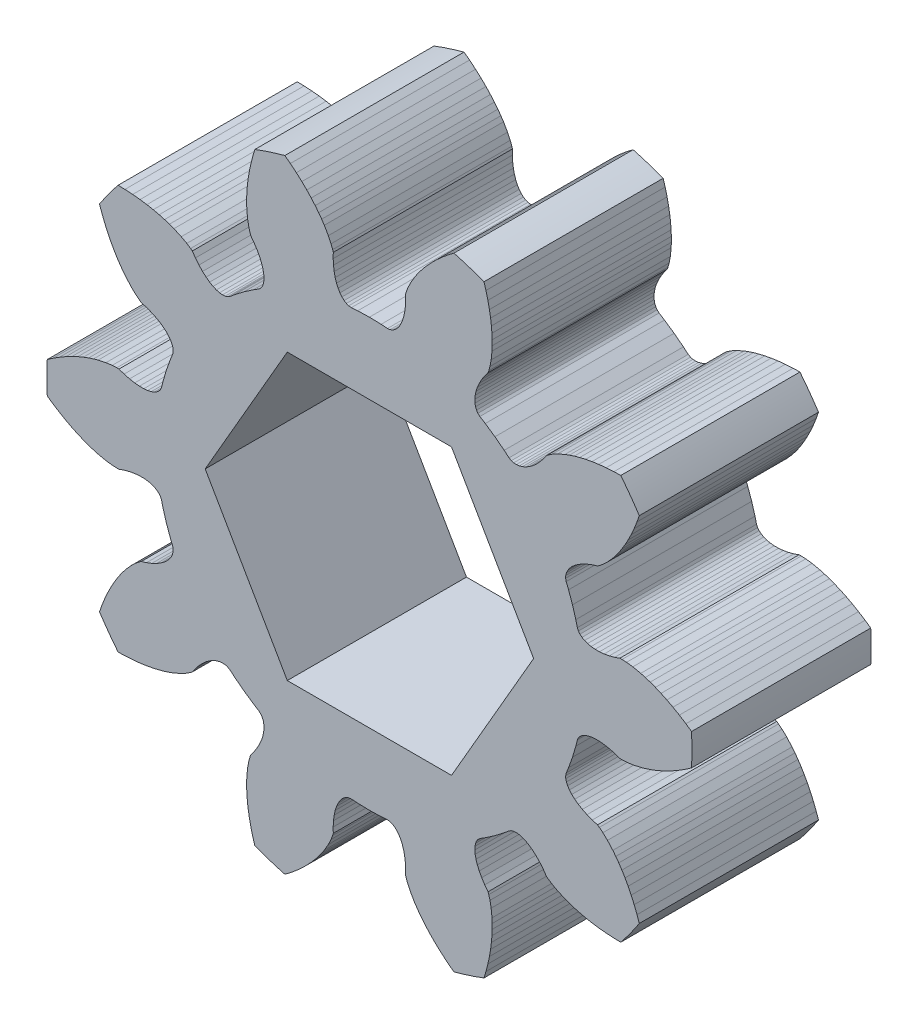
from build123d import *

# Parameters (mm, degrees)
BOSS_EXTRUDE1_DEPTH = 3


with BuildPart() as part:
    # Model → Boss-Extrude1 (new body, symmetric)
    with BuildSketch(Plane.XY):
        with BuildLine():
            Line((8.9615234, 5.6957215), (8.8657208, 5.4530286))
            Line((8.8657208, 5.4530286), (8.7654123, 5.227083))
            Line((8.7654123, 5.227083), (8.6629778, 5.0201721))
            Line((8.6629778, 5.0201721), (8.5591228, 4.8306744))
            Line((8.5591228, 4.8306744), (8.4540092, 4.6566029))
            Line((8.4540092, 4.6566029), (8.3503228, 4.5001444))
            Line((8.3503228, 4.5001444), (8.2497142, 4.3612991))
            Line((8.2497142, 4.3612991), (8.1507015, 4.2360525))
            Line((8.1507015, 4.2360525), (7.9707853, 4.0353208))
            Line((7.9707853, 4.0353208), (7.8171849, 3.8902241))
            Line((7.8171849, 3.8902241), (7.6984707, 3.7953878))
            Line((7.6984707, 3.7953878), (7.6379027, 3.7538481))
            Line((7.6379027, 3.7538481), (7.4633429, 3.7005054))
            Line((7.4633429, 3.7005054), (7.2880277, 3.6330485))
            Line((7.2880277, 3.6330485), (7.1314652, 3.5580682))
            Line((7.1314652, 3.5580682), (6.9939731, 3.4770137))
            Line((6.9939731, 3.4770137), (6.8757521, 3.3913382))
            Line((6.8757521, 3.3913382), (6.7769085, 3.3025271))
            Line((6.7769085, 3.3025271), (6.6974849, 3.2120348))
            Line((6.6974849, 3.2120348), (6.6374198, 3.121345))
            Line((6.6374198, 3.121345), (6.5965502, 3.0318978))
            Line((6.5965502, 3.0318978), (6.5746533, 2.9451558))
            Line((6.5746533, 2.9451558), (6.5714011, 2.8625161))
            Line((6.5714011, 2.8625161), (6.5895052, 2.7762168))
            Line((6.5895052, 2.7762168), (6.6688945, 2.5785132))
            Line((6.6688945, 2.5785132), (6.8000541, 2.2094715))
            Line((6.8000541, 2.2094715), (6.910861, 1.8338169))
            Line((6.910861, 1.8338169), (6.962841, 1.6272074))
            Line((6.962841, 1.6272074), (6.99892, 1.5467485))
            Line((6.99892, 1.5467485), (7.0501253, 1.4818032))
            Line((7.0501253, 1.4818032), (7.118826, 1.4244981))
            Line((7.118826, 1.4244981), (7.204466, 1.3761563))
            Line((7.204466, 1.3761563), (7.3063658, 1.3380921))
            Line((7.3063658, 1.3380921), (7.4238109, 1.3115663))
            Line((7.4238109, 1.3115663), (7.5559789, 1.2978155))
            Line((7.5559789, 1.2978155), (7.7019805, 1.2979911))
            Line((7.7019805, 1.2979911), (7.8608566, 1.3132324))
            Line((7.8608566, 1.3132324), (8.0315906, 1.3445973))
            Line((8.0315906, 1.3445973), (8.2130738, 1.3930711))
            Line((8.2130738, 1.3930711), (8.3856497, 1.4525196))
            Line((8.3856497, 1.4525196), (8.4590665, 1.4545143))
            Line((8.4590665, 1.4545143), (8.6108518, 1.4475686))
            Line((8.6108518, 1.4475686), (8.8204028, 1.420467))
            Line((8.8204028, 1.420467), (9.0839452, 1.3638237))
            Line((9.0839452, 1.3638237), (9.2376663, 1.3206953))
            Line((9.2376663, 1.3206953), (9.4006716, 1.2675033))
            Line((9.4006716, 1.2675033), (9.5765196, 1.2018711))
            Line((9.5765196, 1.2018711), (9.763875, 1.1228284))
            Line((9.763875, 1.1228284), (9.9592794, 1.0305661))
            Line((9.9592794, 1.0305661), (10.1637699, 0.9233811))
            Line((10.1637699, 0.9233811), (10.3777285, 0.7995471))
            Line((10.3777285, 0.7995471), (10.5978859, 0.6595158))
            Line((10.5978859, 0.6595158), (10.7870004, 0.5284416))
            ThreePointArc((10.7870004, 0.5284416), (10.799936412, 0), (10.7870004, -0.5284416))
            Line((10.7870004, -0.5284416), (10.5978859, -0.6595158))
            Line((10.5978859, -0.6595158), (10.3777285, -0.7995471))
            Line((10.3777285, -0.7995471), (10.1637699, -0.9233811))
            Line((10.1637699, -0.9233811), (9.9592794, -1.0305661))
            Line((9.9592794, -1.0305661), (9.763875, -1.1228284))
            Line((9.763875, -1.1228284), (9.5765196, -1.2018711))
            Line((9.5765196, -1.2018711), (9.4006716, -1.2675033))
            Line((9.4006716, -1.2675033), (9.2376663, -1.3206953))
            Line((9.2376663, -1.3206953), (9.0839452, -1.3638237))
            Line((9.0839452, -1.3638237), (8.8204028, -1.420467))
            Line((8.8204028, -1.420467), (8.6108518, -1.4475686))
            Line((8.6108518, -1.4475686), (8.4590665, -1.4545143))
            Line((8.4590665, -1.4545143), (8.3856497, -1.4525196))
            Line((8.3856497, -1.4525196), (8.2130738, -1.3930711))
            Line((8.2130738, -1.3930711), (8.0315906, -1.3445973))
            Line((8.0315906, -1.3445973), (7.8608566, -1.3132324))
            Line((7.8608566, -1.3132324), (7.7019805, -1.2979911))
            Line((7.7019805, -1.2979911), (7.5559789, -1.2978155))
            Line((7.5559789, -1.2978155), (7.4238109, -1.3115663))
            Line((7.4238109, -1.3115663), (7.3063658, -1.3380921))
            Line((7.3063658, -1.3380921), (7.204466, -1.3761563))
            Line((7.204466, -1.3761563), (7.118826, -1.4244981))
            Line((7.118826, -1.4244981), (7.0501253, -1.4818032))
            Line((7.0501253, -1.4818032), (6.99892, -1.5467485))
            Line((6.99892, -1.5467485), (6.962841, -1.6272074))
            Line((6.962841, -1.6272074), (6.910861, -1.8338169))
            Line((6.910861, -1.8338169), (6.8000541, -2.2094715))
            Line((6.8000541, -2.2094715), (6.6688945, -2.5785132))
            Line((6.6688945, -2.5785132), (6.5895052, -2.7762168))
            Line((6.5895052, -2.7762168), (6.5714011, -2.8625161))
            Line((6.5714011, -2.8625161), (6.5746533, -2.9451558))
            Line((6.5746533, -2.9451558), (6.5965502, -3.0318978))
            Line((6.5965502, -3.0318978), (6.6374198, -3.121345))
            Line((6.6374198, -3.121345), (6.6974849, -3.2120348))
            Line((6.6974849, -3.2120348), (6.7769085, -3.3025271))
            Line((6.7769085, -3.3025271), (6.8757521, -3.3913382))
            Line((6.8757521, -3.3913382), (6.9939731, -3.4770137))
            Line((6.9939731, -3.4770137), (7.1314652, -3.5580682))
            Line((7.1314652, -3.5580682), (7.2880277, -3.6330485))
            Line((7.2880277, -3.6330485), (7.4633429, -3.7005054))
            Line((7.4633429, -3.7005054), (7.6379027, -3.7538481))
            Line((7.6379027, -3.7538481), (7.6984707, -3.7953878))
            Line((7.6984707, -3.7953878), (7.8171849, -3.8902241))
            Line((7.8171849, -3.8902241), (7.9707853, -4.0353208))
            Line((7.9707853, -4.0353208), (8.1507015, -4.2360525))
            Line((8.1507015, -4.2360525), (8.2497142, -4.3612991))
            Line((8.2497142, -4.3612991), (8.3503228, -4.5001444))
            Line((8.3503228, -4.5001444), (8.4540092, -4.6566029))
            Line((8.4540092, -4.6566029), (8.5591228, -4.8306744))
            Line((8.5591228, -4.8306744), (8.6629778, -5.0201721))
            Line((8.6629778, -5.0201721), (8.7654123, -5.227083))
            Line((8.7654123, -5.227083), (8.8657208, -5.4530286))
            Line((8.8657208, -5.4530286), (8.9615234, -5.6957215))
            Line((8.9615234, -5.6957215), (9.0374768, -5.9129215))
            ThreePointArc((9.0374768, -5.9129215), (8.737332104, -6.348043346), (8.4162565, -6.767958))
            Line((8.4162565, -6.767958), (8.1862161, -6.7628405))
            Line((8.1862161, -6.7628405), (7.9257968, -6.746723))
            Line((7.9257968, -6.746723), (7.6799127, -6.721145))
            Line((7.6799127, -6.721145), (7.4514747, -6.687663))
            Line((7.4514747, -6.687663), (7.2391588, -6.647449))
            Line((7.2391588, -6.647449), (7.041125, -6.6012711))
            Line((7.041125, -6.6012711), (6.8602833, -6.5510078))
            Line((6.8602833, -6.5510078), (6.6971438, -6.4982289))
            Line((6.6971438, -6.4982289), (6.5474306, -6.4427656))
            Line((6.5474306, -6.4427656), (6.3009262, -6.3336846))
            Line((6.3009262, -6.3336846), (6.115466, -6.2324393))
            Line((6.115466, -6.2324393), (5.9885865, -6.1488414))
            Line((5.9885865, -6.1488414), (5.9303635, -6.1040743))
            Line((5.9303635, -6.1040743), (5.8256896, -5.9545419))
            Line((5.8256896, -5.9545419), (5.7073589, -5.8086526))
            Line((5.7073589, -5.8086526), (5.5876679, -5.6829229))
            Line((5.5876679, -5.6829229), (5.4680931, -5.5772074))
            Line((5.4680931, -5.5772074), (5.3500785, -5.4912477))
            Line((5.3500785, -5.4912477), (5.2350698, -5.424686))
            Line((5.2350698, -5.424686), (5.1244633, -5.3771133))
            Line((5.1244633, -5.3771133), (5.019651, -5.3480127))
            Line((5.019651, -5.3480127), (4.9219522, -5.3367841))
            Line((4.9219522, -5.3367841), (4.8326892, -5.3427636))
            Line((4.8326892, -5.3427636), (4.7530893, -5.3652077))
            Line((4.7530893, -5.3652077), (4.6766082, -5.4090937))
            Line((4.6766082, -5.4090937), (4.5131135, -5.5456912))
            Line((4.5131135, -5.5456912), (4.2026646, -5.7844715))
            Line((4.2026646, -5.7844715), (3.879637, -6.0059388))
            Line((3.879637, -6.0059388), (3.6992024, -6.1192205))
            Line((3.6992024, -6.1192205), (3.6338304, -6.1783969))
            Line((3.6338304, -6.1783969), (3.5878871, -6.2471653))
            Line((3.5878871, -6.2471653), (3.5546164, -6.3302117))
            Line((3.5546164, -6.3302117), (3.5351048, -6.4265986))
            Line((3.5351048, -6.4265986), (3.5303924, -6.5352736))
            Line((3.5303924, -6.5352736), (3.5414574, -6.6551674))
            Line((3.5414574, -6.6551674), (3.5692218, -6.7851159))
            Line((3.5692218, -6.7851159), (3.6145057, -6.9239174))
            Line((3.6145057, -6.9239174), (3.6780965, -7.0703077))
            Line((3.6780965, -7.0703077), (3.760686, -7.2229932))
            Line((3.760686, -7.2229932), (3.8628688, -7.3806147))
            Line((3.8628688, -7.3806147), (3.9727365, -7.5263735))
            Line((3.9727365, -7.5263735), (3.9973206, -7.5955807))
            Line((3.9973206, -7.5955807), (4.0376191, -7.7420834))
            Line((4.0376191, -7.7420834), (4.0765987, -7.9497531))
            Line((4.0765987, -7.9497531), (4.1041669, -8.2179006))
            Line((4.1041669, -8.2179006), (4.1106517, -8.3774254))
            Line((4.1106517, -8.3774254), (4.1104345, -8.5488899))
            Line((4.1104345, -8.5488899), (4.1023546, -8.7364128))
            Line((4.1023546, -8.7364128), (4.0850766, -8.9390239))
            Line((4.0850766, -8.9390239), (4.0577132, -9.1533751))
            Line((4.0577132, -9.1533751), (4.0189652, -9.3809791))
            Line((4.0189652, -9.3809791), (3.967309, -9.6227327))
            Line((3.967309, -9.6227327), (3.9021637, -9.8753868))
            Line((3.9021637, -9.8753868), (3.8359442, -10.0957496))
            ThreePointArc((3.8359442, -10.0957496), (3.337363848, -10.271349928), (2.8307886, -10.4223445))
            Line((2.8307886, -10.4223445), (2.64769, -10.28299))
            Line((2.64769, -10.28299), (2.44648, -10.11688))
            Line((2.44648, -10.11688), (2.26259, -9.95166))
            Line((2.26259, -9.95166), (2.09746, -9.7903))
            Line((2.09746, -9.7903), (1.94933, -9.63297))
            Line((1.94933, -9.63297), (1.81626, -9.47921))
            Line((1.81626, -9.47921), (1.6995, -9.33225))
            Line((1.6995, -9.33225), (1.59854, -9.19366))
            Line((1.59854, -9.19366), (1.51002, -9.06079))
            Line((1.51002, -9.06079), (1.37471, -8.82765))
            Line((1.37471, -8.82765), (1.28418, -8.63673))
            Line((1.28418, -8.63673), (1.23067, -8.49452))
            Line((1.23067, -8.49452), (1.20988, -8.42408))
            Line((1.20988, -8.42408), (1.21309, -8.24158))
            Line((1.21309, -8.24158), (1.20311, -8.054))
            Line((1.20311, -8.054), (1.18018, -7.88193))
            Line((1.18018, -7.88193), (1.14558, -7.72612))
            Line((1.14558, -7.72612), (1.10063, -7.58721))
            Line((1.10063, -7.58721), (1.04671, -7.46576))
            Line((1.04671, -7.46576), (0.98519, -7.36226))
            Line((0.98519, -7.36226), (0.9175, -7.27711))
            Line((0.9175, -7.27711), (0.84506, -7.2106))
            Line((0.84506, -7.2106), (0.76933, -7.16297))
            Line((0.76933, -7.16297), (0.69174, -7.13434))
            Line((0.69174, -7.13434), (0.60407, -7.12489))
            Line((0.60407, -7.12489), (0.39151, -7.1393))
            Line((0.39151, -7.1393), (0, -7.15))
            Line((0, -7.15), (-0.39151, -7.1393))
            Line((-0.39151, -7.1393), (-0.60407, -7.12489))
            Line((-0.60407, -7.12489), (-0.69174, -7.13434))
            Line((-0.69174, -7.13434), (-0.76933, -7.16297))
            Line((-0.76933, -7.16297), (-0.84506, -7.2106))
            Line((-0.84506, -7.2106), (-0.9175, -7.27711))
            Line((-0.9175, -7.27711), (-0.98519, -7.36226))
            Line((-0.98519, -7.36226), (-1.04671, -7.46576))
            Line((-1.04671, -7.46576), (-1.10063, -7.58721))
            Line((-1.10063, -7.58721), (-1.14558, -7.72612))
            Line((-1.14558, -7.72612), (-1.18018, -7.88193))
            Line((-1.18018, -7.88193), (-1.20311, -8.054))
            Line((-1.20311, -8.054), (-1.21309, -8.24158))
            Line((-1.21309, -8.24158), (-1.20988, -8.42408))
            Line((-1.20988, -8.42408), (-1.23067, -8.49452))
            Line((-1.23067, -8.49452), (-1.28418, -8.63673))
            Line((-1.28418, -8.63673), (-1.37471, -8.82765))
            Line((-1.37471, -8.82765), (-1.51002, -9.06079))
            Line((-1.51002, -9.06079), (-1.59854, -9.19366))
            Line((-1.59854, -9.19366), (-1.6995, -9.33225))
            Line((-1.6995, -9.33225), (-1.81626, -9.47921))
            Line((-1.81626, -9.47921), (-1.94933, -9.63297))
            Line((-1.94933, -9.63297), (-2.09746, -9.7903))
            Line((-2.09746, -9.7903), (-2.26259, -9.95166))
            Line((-2.26259, -9.95166), (-2.44648, -10.11688))
            Line((-2.44648, -10.11688), (-2.64769, -10.28299))
            Line((-2.64769, -10.28299), (-2.8307886, -10.4223445))
            ThreePointArc((-2.8307886, -10.4223445), (-3.337363848, -10.271349928), (-3.8359442, -10.0957496))
            Line((-3.8359442, -10.0957496), (-3.9021637, -9.8753868))
            Line((-3.9021637, -9.8753868), (-3.967309, -9.6227327))
            Line((-3.967309, -9.6227327), (-4.0189652, -9.3809791))
            Line((-4.0189652, -9.3809791), (-4.0577132, -9.1533751))
            Line((-4.0577132, -9.1533751), (-4.0850766, -8.9390239))
            Line((-4.0850766, -8.9390239), (-4.1023546, -8.7364128))
            Line((-4.1023546, -8.7364128), (-4.1104345, -8.5488899))
            Line((-4.1104345, -8.5488899), (-4.1106517, -8.3774254))
            Line((-4.1106517, -8.3774254), (-4.1041669, -8.2179006))
            Line((-4.1041669, -8.2179006), (-4.0765987, -7.9497531))
            Line((-4.0765987, -7.9497531), (-4.0376191, -7.7420834))
            Line((-4.0376191, -7.7420834), (-3.9973206, -7.5955807))
            Line((-3.9973206, -7.5955807), (-3.9727365, -7.5263735))
            Line((-3.9727365, -7.5263735), (-3.8628688, -7.3806147))
            Line((-3.8628688, -7.3806147), (-3.760686, -7.2229932))
            Line((-3.760686, -7.2229932), (-3.6780965, -7.0703077))
            Line((-3.6780965, -7.0703077), (-3.6145057, -6.9239174))
            Line((-3.6145057, -6.9239174), (-3.5692218, -6.7851159))
            Line((-3.5692218, -6.7851159), (-3.5414574, -6.6551674))
            Line((-3.5414574, -6.6551674), (-3.5303924, -6.5352736))
            Line((-3.5303924, -6.5352736), (-3.5351048, -6.4265986))
            Line((-3.5351048, -6.4265986), (-3.5546164, -6.3302117))
            Line((-3.5546164, -6.3302117), (-3.5878871, -6.2471653))
            Line((-3.5878871, -6.2471653), (-3.6338304, -6.1783969))
            Line((-3.6338304, -6.1783969), (-3.6992024, -6.1192205))
            Line((-3.6992024, -6.1192205), (-3.879637, -6.0059388))
            Line((-3.879637, -6.0059388), (-4.2026646, -5.7844715))
            Line((-4.2026646, -5.7844715), (-4.5131135, -5.5456912))
            Line((-4.5131135, -5.5456912), (-4.6766082, -5.4090937))
            Line((-4.6766082, -5.4090937), (-4.7530893, -5.3652077))
            Line((-4.7530893, -5.3652077), (-4.8326892, -5.3427636))
            Line((-4.8326892, -5.3427636), (-4.9219522, -5.3367841))
            Line((-4.9219522, -5.3367841), (-5.019651, -5.3480127))
            Line((-5.019651, -5.3480127), (-5.1244633, -5.3771133))
            Line((-5.1244633, -5.3771133), (-5.2350698, -5.424686))
            Line((-5.2350698, -5.424686), (-5.3500785, -5.4912477))
            Line((-5.3500785, -5.4912477), (-5.4680931, -5.5772074))
            Line((-5.4680931, -5.5772074), (-5.5876679, -5.6829229))
            Line((-5.5876679, -5.6829229), (-5.7073589, -5.8086526))
            Line((-5.7073589, -5.8086526), (-5.8256896, -5.9545419))
            Line((-5.8256896, -5.9545419), (-5.9303635, -6.1040743))
            Line((-5.9303635, -6.1040743), (-5.9885865, -6.1488414))
            Line((-5.9885865, -6.1488414), (-6.115466, -6.2324393))
            Line((-6.115466, -6.2324393), (-6.3009262, -6.3336846))
            Line((-6.3009262, -6.3336846), (-6.5474306, -6.4427656))
            Line((-6.5474306, -6.4427656), (-6.6971438, -6.4982289))
            Line((-6.6971438, -6.4982289), (-6.8602833, -6.5510078))
            Line((-6.8602833, -6.5510078), (-7.041125, -6.6012711))
            Line((-7.041125, -6.6012711), (-7.2391588, -6.647449))
            Line((-7.2391588, -6.647449), (-7.4514747, -6.687663))
            Line((-7.4514747, -6.687663), (-7.6799127, -6.721145))
            Line((-7.6799127, -6.721145), (-7.9257968, -6.746723))
            Line((-7.9257968, -6.746723), (-8.1862161, -6.7628405))
            Line((-8.1862161, -6.7628405), (-8.4162565, -6.767958))
            ThreePointArc((-8.4162565, -6.767958), (-8.737332104, -6.348043346), (-9.0374768, -5.9129215))
            Line((-9.0374768, -5.9129215), (-8.9615234, -5.6957215))
            Line((-8.9615234, -5.6957215), (-8.8657208, -5.4530286))
            Line((-8.8657208, -5.4530286), (-8.7654123, -5.227083))
            Line((-8.7654123, -5.227083), (-8.6629778, -5.0201721))
            Line((-8.6629778, -5.0201721), (-8.5591228, -4.8306744))
            Line((-8.5591228, -4.8306744), (-8.4540092, -4.6566029))
            Line((-8.4540092, -4.6566029), (-8.3503228, -4.5001444))
            Line((-8.3503228, -4.5001444), (-8.2497142, -4.3612991))
            Line((-8.2497142, -4.3612991), (-8.1507015, -4.2360525))
            Line((-8.1507015, -4.2360525), (-7.9707853, -4.0353208))
            Line((-7.9707853, -4.0353208), (-7.8171849, -3.8902241))
            Line((-7.8171849, -3.8902241), (-7.6984707, -3.7953878))
            Line((-7.6984707, -3.7953878), (-7.6379027, -3.7538481))
            Line((-7.6379027, -3.7538481), (-7.4633429, -3.7005054))
            Line((-7.4633429, -3.7005054), (-7.2880277, -3.6330485))
            Line((-7.2880277, -3.6330485), (-7.1314652, -3.5580682))
            Line((-7.1314652, -3.5580682), (-6.9939731, -3.4770137))
            Line((-6.9939731, -3.4770137), (-6.8757521, -3.3913382))
            Line((-6.8757521, -3.3913382), (-6.7769085, -3.3025271))
            Line((-6.7769085, -3.3025271), (-6.6974849, -3.2120348))
            Line((-6.6974849, -3.2120348), (-6.6374198, -3.121345))
            Line((-6.6374198, -3.121345), (-6.5965502, -3.0318978))
            Line((-6.5965502, -3.0318978), (-6.5746533, -2.9451558))
            Line((-6.5746533, -2.9451558), (-6.5714011, -2.8625161))
            Line((-6.5714011, -2.8625161), (-6.5895052, -2.7762168))
            Line((-6.5895052, -2.7762168), (-6.6688945, -2.5785132))
            Line((-6.6688945, -2.5785132), (-6.8000541, -2.2094715))
            Line((-6.8000541, -2.2094715), (-6.910861, -1.8338169))
            Line((-6.910861, -1.8338169), (-6.962841, -1.6272074))
            Line((-6.962841, -1.6272074), (-6.99892, -1.5467485))
            Line((-6.99892, -1.5467485), (-7.0501253, -1.4818032))
            Line((-7.0501253, -1.4818032), (-7.118826, -1.4244981))
            Line((-7.118826, -1.4244981), (-7.204466, -1.3761563))
            Line((-7.204466, -1.3761563), (-7.3063658, -1.3380921))
            Line((-7.3063658, -1.3380921), (-7.4238109, -1.3115663))
            Line((-7.4238109, -1.3115663), (-7.5559789, -1.2978155))
            Line((-7.5559789, -1.2978155), (-7.7019805, -1.2979911))
            Line((-7.7019805, -1.2979911), (-7.8608566, -1.3132324))
            Line((-7.8608566, -1.3132324), (-8.0315906, -1.3445973))
            Line((-8.0315906, -1.3445973), (-8.2130738, -1.3930711))
            Line((-8.2130738, -1.3930711), (-8.3856497, -1.4525196))
            Line((-8.3856497, -1.4525196), (-8.4590665, -1.4545143))
            Line((-8.4590665, -1.4545143), (-8.6108518, -1.4475686))
            Line((-8.6108518, -1.4475686), (-8.8204028, -1.420467))
            Line((-8.8204028, -1.420467), (-9.0839452, -1.3638237))
            Line((-9.0839452, -1.3638237), (-9.2376663, -1.3206953))
            Line((-9.2376663, -1.3206953), (-9.4006716, -1.2675033))
            Line((-9.4006716, -1.2675033), (-9.5765196, -1.2018711))
            Line((-9.5765196, -1.2018711), (-9.763875, -1.1228284))
            Line((-9.763875, -1.1228284), (-9.9592794, -1.0305661))
            Line((-9.9592794, -1.0305661), (-10.1637699, -0.9233811))
            Line((-10.1637699, -0.9233811), (-10.3777285, -0.7995471))
            Line((-10.3777285, -0.7995471), (-10.5978859, -0.6595158))
            Line((-10.5978859, -0.6595158), (-10.7870004, -0.5284416))
            ThreePointArc((-10.7870004, -0.5284416), (-10.799936412, 0), (-10.7870004, 0.5284416))
            Line((-10.7870004, 0.5284416), (-10.5978859, 0.6595158))
            Line((-10.5978859, 0.6595158), (-10.3777285, 0.7995471))
            Line((-10.3777285, 0.7995471), (-10.1637699, 0.9233811))
            Line((-10.1637699, 0.9233811), (-9.9592794, 1.0305661))
            Line((-9.9592794, 1.0305661), (-9.763875, 1.1228284))
            Line((-9.763875, 1.1228284), (-9.5765196, 1.2018711))
            Line((-9.5765196, 1.2018711), (-9.4006716, 1.2675033))
            Line((-9.4006716, 1.2675033), (-9.2376663, 1.3206953))
            Line((-9.2376663, 1.3206953), (-9.0839452, 1.3638237))
            Line((-9.0839452, 1.3638237), (-8.8204028, 1.420467))
            Line((-8.8204028, 1.420467), (-8.6108518, 1.4475686))
            Line((-8.6108518, 1.4475686), (-8.4590665, 1.4545143))
            Line((-8.4590665, 1.4545143), (-8.3856497, 1.4525196))
            Line((-8.3856497, 1.4525196), (-8.2130738, 1.3930711))
            Line((-8.2130738, 1.3930711), (-8.0315906, 1.3445973))
            Line((-8.0315906, 1.3445973), (-7.8608566, 1.3132324))
            Line((-7.8608566, 1.3132324), (-7.7019805, 1.2979911))
            Line((-7.7019805, 1.2979911), (-7.5559789, 1.2978155))
            Line((-7.5559789, 1.2978155), (-7.4238109, 1.3115663))
            Line((-7.4238109, 1.3115663), (-7.3063658, 1.3380921))
            Line((-7.3063658, 1.3380921), (-7.204466, 1.3761563))
            Line((-7.204466, 1.3761563), (-7.118826, 1.4244981))
            Line((-7.118826, 1.4244981), (-7.0501253, 1.4818032))
            Line((-7.0501253, 1.4818032), (-6.99892, 1.5467485))
            Line((-6.99892, 1.5467485), (-6.962841, 1.6272074))
            Line((-6.962841, 1.6272074), (-6.910861, 1.8338169))
            Line((-6.910861, 1.8338169), (-6.8000541, 2.2094715))
            Line((-6.8000541, 2.2094715), (-6.6688945, 2.5785132))
            Line((-6.6688945, 2.5785132), (-6.5895052, 2.7762168))
            Line((-6.5895052, 2.7762168), (-6.5714011, 2.8625161))
            Line((-6.5714011, 2.8625161), (-6.5746533, 2.9451558))
            Line((-6.5746533, 2.9451558), (-6.5965502, 3.0318978))
            Line((-6.5965502, 3.0318978), (-6.6374198, 3.121345))
            Line((-6.6374198, 3.121345), (-6.6974849, 3.2120348))
            Line((-6.6974849, 3.2120348), (-6.7769085, 3.3025271))
            Line((-6.7769085, 3.3025271), (-6.8757521, 3.3913382))
            Line((-6.8757521, 3.3913382), (-6.9939731, 3.4770137))
            Line((-6.9939731, 3.4770137), (-7.1314652, 3.5580682))
            Line((-7.1314652, 3.5580682), (-7.2880277, 3.6330485))
            Line((-7.2880277, 3.6330485), (-7.4633429, 3.7005054))
            Line((-7.4633429, 3.7005054), (-7.6379027, 3.7538481))
            Line((-7.6379027, 3.7538481), (-7.6984707, 3.7953878))
            Line((-7.6984707, 3.7953878), (-7.8171849, 3.8902241))
            Line((-7.8171849, 3.8902241), (-7.9707853, 4.0353208))
            Line((-7.9707853, 4.0353208), (-8.1507015, 4.2360525))
            Line((-8.1507015, 4.2360525), (-8.2497142, 4.3612991))
            Line((-8.2497142, 4.3612991), (-8.3503228, 4.5001444))
            Line((-8.3503228, 4.5001444), (-8.4540092, 4.6566029))
            Line((-8.4540092, 4.6566029), (-8.5591228, 4.8306744))
            Line((-8.5591228, 4.8306744), (-8.6629778, 5.0201721))
            Line((-8.6629778, 5.0201721), (-8.7654123, 5.227083))
            Line((-8.7654123, 5.227083), (-8.8657208, 5.4530286))
            Line((-8.8657208, 5.4530286), (-8.9615234, 5.6957215))
            Line((-8.9615234, 5.6957215), (-9.0374768, 5.9129215))
            ThreePointArc((-9.0374768, 5.9129215), (-8.737332104, 6.348043346), (-8.4162565, 6.767958))
            Line((-8.4162565, 6.767958), (-8.1862161, 6.7628405))
            Line((-8.1862161, 6.7628405), (-7.9257968, 6.746723))
            Line((-7.9257968, 6.746723), (-7.6799127, 6.721145))
            Line((-7.6799127, 6.721145), (-7.4514747, 6.687663))
            Line((-7.4514747, 6.687663), (-7.2391588, 6.647449))
            Line((-7.2391588, 6.647449), (-7.041125, 6.6012711))
            Line((-7.041125, 6.6012711), (-6.8602833, 6.5510078))
            Line((-6.8602833, 6.5510078), (-6.6971438, 6.4982289))
            Line((-6.6971438, 6.4982289), (-6.5474306, 6.4427656))
            Line((-6.5474306, 6.4427656), (-6.3009262, 6.3336846))
            Line((-6.3009262, 6.3336846), (-6.115466, 6.2324393))
            Line((-6.115466, 6.2324393), (-5.9885865, 6.1488414))
            Line((-5.9885865, 6.1488414), (-5.9303635, 6.1040743))
            Line((-5.9303635, 6.1040743), (-5.8256896, 5.9545419))
            Line((-5.8256896, 5.9545419), (-5.7073589, 5.8086526))
            Line((-5.7073589, 5.8086526), (-5.5876679, 5.6829229))
            Line((-5.5876679, 5.6829229), (-5.4680931, 5.5772074))
            Line((-5.4680931, 5.5772074), (-5.3500785, 5.4912477))
            Line((-5.3500785, 5.4912477), (-5.2350698, 5.424686))
            Line((-5.2350698, 5.424686), (-5.1244633, 5.3771133))
            Line((-5.1244633, 5.3771133), (-5.019651, 5.3480127))
            Line((-5.019651, 5.3480127), (-4.9219522, 5.3367841))
            Line((-4.9219522, 5.3367841), (-4.8326892, 5.3427636))
            Line((-4.8326892, 5.3427636), (-4.7530893, 5.3652077))
            Line((-4.7530893, 5.3652077), (-4.6766082, 5.4090937))
            Line((-4.6766082, 5.4090937), (-4.5131135, 5.5456912))
            Line((-4.5131135, 5.5456912), (-4.2026646, 5.7844715))
            Line((-4.2026646, 5.7844715), (-3.879637, 6.0059388))
            Line((-3.879637, 6.0059388), (-3.6992024, 6.1192205))
            Line((-3.6992024, 6.1192205), (-3.6338304, 6.1783969))
            Line((-3.6338304, 6.1783969), (-3.5878871, 6.2471653))
            Line((-3.5878871, 6.2471653), (-3.5546164, 6.3302117))
            Line((-3.5546164, 6.3302117), (-3.5351048, 6.4265986))
            Line((-3.5351048, 6.4265986), (-3.5303924, 6.5352736))
            Line((-3.5303924, 6.5352736), (-3.5414574, 6.6551674))
            Line((-3.5414574, 6.6551674), (-3.5692218, 6.7851159))
            Line((-3.5692218, 6.7851159), (-3.6145057, 6.9239174))
            Line((-3.6145057, 6.9239174), (-3.6780965, 7.0703077))
            Line((-3.6780965, 7.0703077), (-3.760686, 7.2229932))
            Line((-3.760686, 7.2229932), (-3.8628688, 7.3806147))
            Line((-3.8628688, 7.3806147), (-3.9727365, 7.5263735))
            Line((-3.9727365, 7.5263735), (-3.9973206, 7.5955807))
            Line((-3.9973206, 7.5955807), (-4.0376191, 7.7420834))
            Line((-4.0376191, 7.7420834), (-4.0765987, 7.9497531))
            Line((-4.0765987, 7.9497531), (-4.1041669, 8.2179006))
            Line((-4.1041669, 8.2179006), (-4.1106517, 8.3774254))
            Line((-4.1106517, 8.3774254), (-4.1104345, 8.5488899))
            Line((-4.1104345, 8.5488899), (-4.1023546, 8.7364128))
            Line((-4.1023546, 8.7364128), (-4.0850766, 8.9390239))
            Line((-4.0850766, 8.9390239), (-4.0577132, 9.1533751))
            Line((-4.0577132, 9.1533751), (-4.0189652, 9.3809791))
            Line((-4.0189652, 9.3809791), (-3.967309, 9.6227327))
            Line((-3.967309, 9.6227327), (-3.9021637, 9.8753868))
            Line((-3.9021637, 9.8753868), (-3.8359442, 10.0957496))
            ThreePointArc((-3.8359442, 10.0957496), (-3.337363848, 10.271349928), (-2.8307886, 10.4223445))
            Line((-2.8307886, 10.4223445), (-2.64769, 10.28299))
            Line((-2.64769, 10.28299), (-2.44648, 10.11688))
            Line((-2.44648, 10.11688), (-2.26259, 9.95166))
            Line((-2.26259, 9.95166), (-2.09746, 9.7903))
            Line((-2.09746, 9.7903), (-1.94933, 9.63297))
            Line((-1.94933, 9.63297), (-1.81626, 9.47921))
            Line((-1.81626, 9.47921), (-1.6995, 9.33225))
            Line((-1.6995, 9.33225), (-1.59854, 9.19366))
            Line((-1.59854, 9.19366), (-1.51002, 9.06079))
            Line((-1.51002, 9.06079), (-1.37471, 8.82765))
            Line((-1.37471, 8.82765), (-1.28418, 8.63673))
            Line((-1.28418, 8.63673), (-1.23067, 8.49452))
            Line((-1.23067, 8.49452), (-1.20988, 8.42408))
            Line((-1.20988, 8.42408), (-1.21309, 8.24158))
            Line((-1.21309, 8.24158), (-1.20311, 8.054))
            Line((-1.20311, 8.054), (-1.18018, 7.88193))
            Line((-1.18018, 7.88193), (-1.14558, 7.72612))
            Line((-1.14558, 7.72612), (-1.10063, 7.58721))
            Line((-1.10063, 7.58721), (-1.04671, 7.46576))
            Line((-1.04671, 7.46576), (-0.98519, 7.36226))
            Line((-0.98519, 7.36226), (-0.9175, 7.27711))
            Line((-0.9175, 7.27711), (-0.84506, 7.2106))
            Line((-0.84506, 7.2106), (-0.76933, 7.16297))
            Line((-0.76933, 7.16297), (-0.69174, 7.13434))
            Line((-0.69174, 7.13434), (-0.60407, 7.12489))
            Line((-0.60407, 7.12489), (-0.39151, 7.1393))
            Line((-0.39151, 7.1393), (0, 7.15))
            Line((0, 7.15), (0.39151, 7.1393))
            Line((0.39151, 7.1393), (0.60407, 7.12489))
            Line((0.60407, 7.12489), (0.69174, 7.13434))
            Line((0.69174, 7.13434), (0.76933, 7.16297))
            Line((0.76933, 7.16297), (0.84506, 7.2106))
            Line((0.84506, 7.2106), (0.9175, 7.27711))
            Line((0.9175, 7.27711), (0.98519, 7.36226))
            Line((0.98519, 7.36226), (1.04671, 7.46576))
            Line((1.04671, 7.46576), (1.10063, 7.58721))
            Line((1.10063, 7.58721), (1.14558, 7.72612))
            Line((1.14558, 7.72612), (1.18018, 7.88193))
            Line((1.18018, 7.88193), (1.20311, 8.054))
            Line((1.20311, 8.054), (1.21309, 8.24158))
            Line((1.21309, 8.24158), (1.20988, 8.42408))
            Line((1.20988, 8.42408), (1.23067, 8.49452))
            Line((1.23067, 8.49452), (1.28418, 8.63673))
            Line((1.28418, 8.63673), (1.37471, 8.82765))
            Line((1.37471, 8.82765), (1.51002, 9.06079))
            Line((1.51002, 9.06079), (1.59854, 9.19366))
            Line((1.59854, 9.19366), (1.6995, 9.33225))
            Line((1.6995, 9.33225), (1.81626, 9.47921))
            Line((1.81626, 9.47921), (1.94933, 9.63297))
            Line((1.94933, 9.63297), (2.09746, 9.7903))
            Line((2.09746, 9.7903), (2.26259, 9.95166))
            Line((2.26259, 9.95166), (2.44648, 10.11688))
            Line((2.44648, 10.11688), (2.64769, 10.28299))
            Line((2.64769, 10.28299), (2.8307886, 10.4223445))
            ThreePointArc((2.8307886, 10.4223445), (3.337363848, 10.271349928), (3.8359442, 10.0957496))
            Line((3.8359442, 10.0957496), (3.9021637, 9.8753868))
            Line((3.9021637, 9.8753868), (3.967309, 9.6227327))
            Line((3.967309, 9.6227327), (4.0189652, 9.3809791))
            Line((4.0189652, 9.3809791), (4.0577132, 9.1533751))
            Line((4.0577132, 9.1533751), (4.0850766, 8.9390239))
            Line((4.0850766, 8.9390239), (4.1023546, 8.7364128))
            Line((4.1023546, 8.7364128), (4.1104345, 8.5488899))
            Line((4.1104345, 8.5488899), (4.1106517, 8.3774254))
            Line((4.1106517, 8.3774254), (4.1041669, 8.2179006))
            Line((4.1041669, 8.2179006), (4.0765987, 7.9497531))
            Line((4.0765987, 7.9497531), (4.0376191, 7.7420834))
            Line((4.0376191, 7.7420834), (3.9973206, 7.5955807))
            Line((3.9973206, 7.5955807), (3.9727365, 7.5263735))
            Line((3.9727365, 7.5263735), (3.8628688, 7.3806147))
            Line((3.8628688, 7.3806147), (3.760686, 7.2229932))
            Line((3.760686, 7.2229932), (3.6780965, 7.0703077))
            Line((3.6780965, 7.0703077), (3.6145057, 6.9239174))
            Line((3.6145057, 6.9239174), (3.5692218, 6.7851159))
            Line((3.5692218, 6.7851159), (3.5414574, 6.6551674))
            Line((3.5414574, 6.6551674), (3.5303924, 6.5352736))
            Line((3.5303924, 6.5352736), (3.5351048, 6.4265986))
            Line((3.5351048, 6.4265986), (3.5546164, 6.3302117))
            Line((3.5546164, 6.3302117), (3.5878871, 6.2471653))
            Line((3.5878871, 6.2471653), (3.6338304, 6.1783969))
            Line((3.6338304, 6.1783969), (3.6992024, 6.1192205))
            Line((3.6992024, 6.1192205), (3.879637, 6.0059388))
            Line((3.879637, 6.0059388), (4.2026646, 5.7844715))
            Line((4.2026646, 5.7844715), (4.5131135, 5.5456912))
            Line((4.5131135, 5.5456912), (4.6766082, 5.4090937))
            Line((4.6766082, 5.4090937), (4.7530893, 5.3652077))
            Line((4.7530893, 5.3652077), (4.8326892, 5.3427636))
            Line((4.8326892, 5.3427636), (4.9219522, 5.3367841))
            Line((4.9219522, 5.3367841), (5.019651, 5.3480127))
            Line((5.019651, 5.3480127), (5.1244633, 5.3771133))
            Line((5.1244633, 5.3771133), (5.2350698, 5.424686))
            Line((5.2350698, 5.424686), (5.3500785, 5.4912477))
            Line((5.3500785, 5.4912477), (5.4680931, 5.5772074))
            Line((5.4680931, 5.5772074), (5.5876679, 5.6829229))
            Line((5.5876679, 5.6829229), (5.7073589, 5.8086526))
            Line((5.7073589, 5.8086526), (5.8256896, 5.9545419))
            Line((5.8256896, 5.9545419), (5.9303635, 6.1040743))
            Line((5.9303635, 6.1040743), (5.9885865, 6.1488414))
            Line((5.9885865, 6.1488414), (6.115466, 6.2324393))
            Line((6.115466, 6.2324393), (6.3009262, 6.3336846))
            Line((6.3009262, 6.3336846), (6.5474306, 6.4427656))
            Line((6.5474306, 6.4427656), (6.6971438, 6.4982289))
            Line((6.6971438, 6.4982289), (6.8602833, 6.5510078))
            Line((6.8602833, 6.5510078), (7.041125, 6.6012711))
            Line((7.041125, 6.6012711), (7.2391588, 6.647449))
            Line((7.2391588, 6.647449), (7.4514747, 6.687663))
            Line((7.4514747, 6.687663), (7.6799127, 6.721145))
            Line((7.6799127, 6.721145), (7.9257968, 6.746723))
            Line((7.9257968, 6.746723), (8.1862161, 6.7628405))
            Line((8.1862161, 6.7628405), (8.4162565, 6.767958))
            ThreePointArc((8.4162565, 6.767958), (8.737332104, 6.348043346), (9.0374768, 5.9129215))
            Line((9.0374768, 5.9129215), (8.9615234, 5.6957215))
        make_face()
        Polygon((2.74965079, 4.762439695), (-2.749610524, 4.762439695), (-5.499241181, -6.0305e-05), (-2.749610524, -4.762560305), (2.74965079, -4.762560305), (5.499281447, -6.0305e-05), align=None, mode=Mode.SUBTRACT)
    extrude(amount=BOSS_EXTRUDE1_DEPTH, both=True)


solid = part.part
